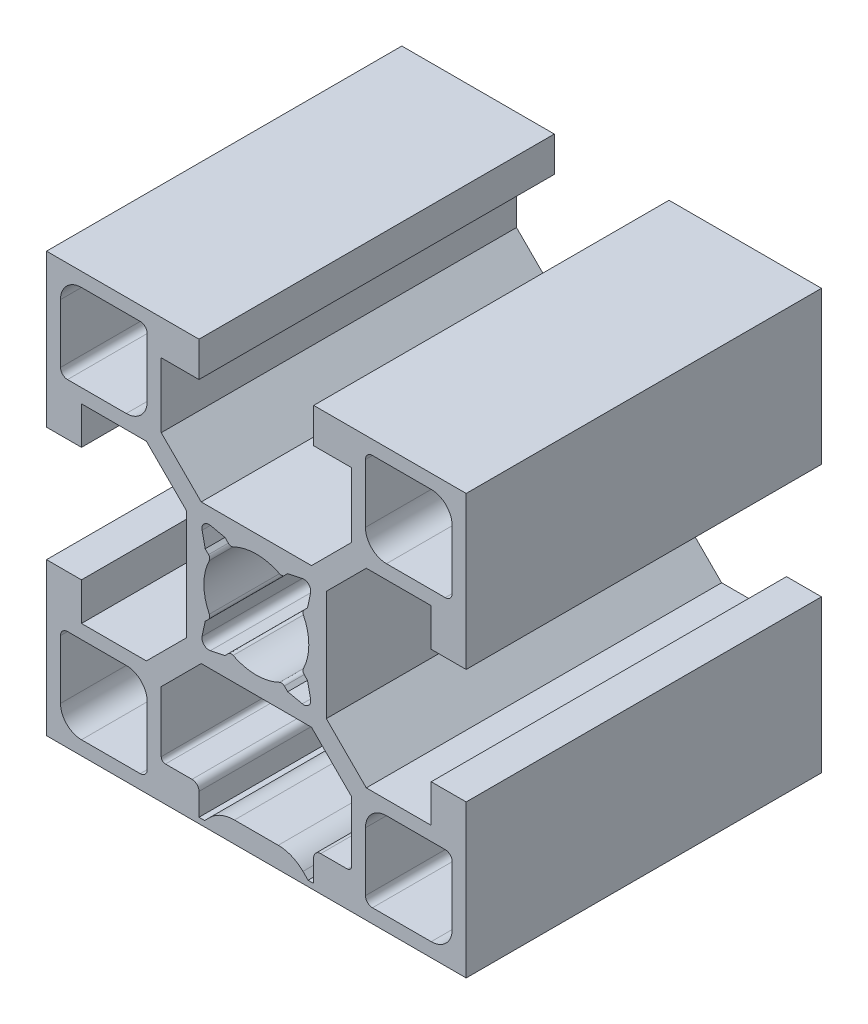
from build123d import *

# Parameters (mm, degrees)
EXTRUSION3_DEPTH = 25.4


with BuildPart() as part:
    # Sketch1 → Extrusion3 (new body)
    with BuildSketch(Plane.XY):
        Polygon((-15.000000011, 14.999999975), (-14.999999998, 4.099998455), (-12.499999998, 4.099998455), (-12.499999998, 6.799995405), (-7.860655598, 6.799995405), (-5.002158168, 3.941497975), (-5.002158168, -3.941498015), (-7.860655598, -6.799995445), (-12.499999998, -6.799995445), (-12.499999998, -4.099998495), (-14.999999998, -4.099998495), (-14.999999998, -15.000000015), (14.999999982, -15.000000015), (14.999999982, -4.099998495), (12.499999982, -4.099998495), (12.499999982, -6.799995445), (7.860655582, -6.799995445), (5.002158152, -3.941498015), (5.002158152, 3.941497975), (7.860655582, 6.799995405), (12.499999982, 6.799995405), (12.499999982, 4.099998455), (14.999999982, 4.099998455), (14.999999982, 14.999999975), (4.099998462, 14.999999975), (4.099998462, 12.499999975), (6.799995412, 12.499999975), (6.799995412, 7.860655575), (3.941497982, 5.002158145), (-3.941498008, 5.002158145), (-6.799995438, 7.860655575), (-6.799995438, 12.499999975), (-4.099998488, 12.499999975), (-4.099998488, 14.999999975), align=None)
        with BuildLine():
            Line((13.499999982, 7.799995395), (9.299995412, 7.799995395))
            ThreePointArc((9.299995412, 7.799995395), (8.239335242, 8.239335225), (7.799995412, 9.299995395))
            Line((7.799995412, 9.299995395), (7.799995412, 13.499999965))
            ThreePointArc((7.799995412, 13.499999965), (7.946442022, 13.853553355), (8.299995412, 13.999999965))
            Line((8.299995412, 13.999999965), (12.499999982, 13.999999965))
            ThreePointArc((12.499999982, 13.999999965), (13.560660152, 13.560660135), (13.999999982, 12.499999965))
            Line((13.999999982, 12.499999965), (13.999999982, 8.299995395))
            ThreePointArc((13.999999982, 8.299995395), (13.853553372, 7.946442005), (13.499999982, 7.799995395))
        make_face(mode=Mode.SUBTRACT)
        with BuildLine():
            Line((-7.799995428, 13.499999965), (-7.799995428, 9.299995395))
            ThreePointArc((-7.799995428, 9.299995395), (-8.239335258, 8.239335225), (-9.299995428, 7.799995395))
            Line((-9.299995428, 7.799995395), (-13.499999998, 7.799995395))
            ThreePointArc((-13.499999998, 7.799995395), (-13.853553388, 7.946442005), (-13.999999998, 8.299995395))
            Line((-13.999999998, 8.299995395), (-13.999999998, 12.499999965))
            ThreePointArc((-13.999999998, 12.499999965), (-13.560660168, 13.560660135), (-12.499999998, 13.999999965))
            Line((-12.499999998, 13.999999965), (-8.299995428, 13.999999965))
            ThreePointArc((-8.299995428, 13.999999965), (-7.946442038, 13.853553355), (-7.799995428, 13.499999965))
        make_face(mode=Mode.SUBTRACT)
        with BuildLine():
            Line((7.799995412, -13.500000015), (7.799995412, -9.299995445))
            ThreePointArc((7.799995412, -9.299995445), (8.239335242, -8.239335275), (9.299995412, -7.799995445))
            Line((9.299995412, -7.799995445), (13.499999982, -7.799995445))
            ThreePointArc((13.499999982, -7.799995445), (13.853553372, -7.946442055), (13.999999982, -8.299995445))
            Line((13.999999982, -8.299995445), (13.999999982, -12.500000015))
            ThreePointArc((13.999999982, -12.500000015), (13.560660152, -13.560660185), (12.499999982, -14.000000015))
            Line((12.499999982, -14.000000015), (8.299995412, -14.000000015))
            ThreePointArc((8.299995412, -14.000000015), (7.946442022, -13.853553405), (7.799995412, -13.500000015))
        make_face(mode=Mode.SUBTRACT)
        with BuildLine():
            Line((-13.499999998, -7.799995445), (-9.299995428, -7.799995445))
            ThreePointArc((-9.299995428, -7.799995445), (-8.239335258, -8.239335275), (-7.799995428, -9.299995445))
            Line((-7.799995428, -9.299995445), (-7.799995428, -13.500000015))
            ThreePointArc((-7.799995428, -13.500000015), (-7.946442038, -13.853553405), (-8.299995428, -14.000000015))
            Line((-8.299995428, -14.000000015), (-12.499999998, -14.000000015))
            ThreePointArc((-12.499999998, -14.000000015), (-13.560660168, -13.560660185), (-13.999999998, -12.500000015))
            Line((-13.999999998, -12.500000015), (-13.999999998, -8.299995445))
            ThreePointArc((-13.999999998, -8.299995445), (-13.853553388, -7.946442055), (-13.499999998, -7.799995445))
        make_face(mode=Mode.SUBTRACT)
        with BuildLine():
            Line((-3.285876608, 3.878886835), (-2.243073548, 3.657287075))
            Line((-2.243073548, 3.657287075), (-2.005134008, 3.419347535))
            ThreePointArc((-2.005134008, 3.419347535), (-1.841800007, 3.335474925), (-1.660187018, 3.362481085))
            ThreePointArc((-1.660187018, 3.362481085), (-2.3e-08, 3.749999985), (1.660186972, 3.362481085))
            ThreePointArc((1.660186972, 3.362481085), (1.841799961, 3.335474925), (2.005133962, 3.419347535))
            Line((2.005133962, 3.419347535), (2.243073502, 3.657287075))
            Line((2.243073502, 3.657287075), (3.285876562, 3.878886835))
            ThreePointArc((3.285876562, 3.878886835), (3.743361172, 3.743361195), (3.878886812, 3.285876585))
            Line((3.878886812, 3.285876585), (3.657287052, 2.243073525))
            Line((3.657287052, 2.243073525), (3.419347512, 2.005133985))
            ThreePointArc((3.419347512, 2.005133985), (3.335474902, 1.841799984), (3.362481062, 1.660186995))
            ThreePointArc((3.362481062, 1.660186995), (3.749999954, -2e-09), (3.362481062, -1.660186995))
            ThreePointArc((3.362481062, -1.660186995), (3.335474902, -1.841799984), (3.419347512, -2.005133985))
            Line((3.419347512, -2.005133985), (3.657287052, -2.243073525))
            Line((3.657287052, -2.243073525), (3.878886812, -3.285876585))
            ThreePointArc((3.878886812, -3.285876585), (3.743361172, -3.743361195), (3.285876562, -3.878886835))
            Line((3.285876562, -3.878886835), (2.243073502, -3.657287075))
            Line((2.243073502, -3.657287075), (2.005133962, -3.419347535))
            ThreePointArc((2.005133962, -3.419347535), (1.841799961, -3.335474925), (1.660186972, -3.362481085))
            ThreePointArc((1.660186972, -3.362481085), (-2.3e-08, -3.74999999), (-1.660187018, -3.362481085))
            ThreePointArc((-1.660187018, -3.362481085), (-1.841800007, -3.335474925), (-2.005134008, -3.419347535))
            Line((-2.005134008, -3.419347535), (-2.243073548, -3.657287075))
            Line((-2.243073548, -3.657287075), (-3.285876608, -3.878886835))
            ThreePointArc((-3.285876608, -3.878886835), (-3.743361218, -3.743361195), (-3.878886858, -3.285876585))
            Line((-3.878886858, -3.285876585), (-3.657287098, -2.243073525))
            Line((-3.657287098, -2.243073525), (-3.419347558, -2.005133985))
            ThreePointArc((-3.419347558, -2.005133985), (-3.335474948, -1.841799984), (-3.362481108, -1.660186995))
            ThreePointArc((-3.362481108, -1.660186995), (-3.750000021, -2e-09), (-3.362481108, 1.660186995))
            ThreePointArc((-3.362481108, 1.660186995), (-3.335474948, 1.841799984), (-3.419347558, 2.005133985))
            Line((-3.419347558, 2.005133985), (-3.657287098, 2.243073525))
            Line((-3.657287098, 2.243073525), (-3.878886858, 3.285876585))
            ThreePointArc((-3.878886858, 3.285876585), (-3.743361218, 3.743361195), (-3.285876608, 3.878886835))
        make_face(mode=Mode.SUBTRACT)
        with BuildLine():
            Line((-6.799995418, -7.860655625), (-3.941497998, -5.002158195))
            Line((-3.941497998, -5.002158195), (3.941497992, -5.002158195))
            Line((3.941497992, -5.002158195), (6.799995422, -7.860655625))
            Line((6.799995422, -7.860655625), (6.799995422, -12.199996975))
            ThreePointArc((6.799995422, -12.199996975), (6.712130925, -12.412130132), (6.500000002, -12.500000025))
            Line((6.500000002, -12.500000025), (4.599998472, -12.500000025))
            ThreePointArc((4.599998472, -12.500000025), (4.246445082, -12.646446635), (4.099998472, -13.000000025))
            Line((4.099998472, -13.000000025), (4.099998472, -14.600000025))
            Line((4.099998472, -14.600000025), (3.699990832, -14.600000025))
            Line((3.699990832, -14.600000025), (3.332307072, -14.232291555))
            ThreePointArc((3.332307072, -14.232291555), (2.521228054, -13.690316336), (1.564480612, -13.499999115))
            Line((1.564480612, -13.499999115), (-5.8e-08, -13.499999185))
            Line((-5.8e-08, -13.499999185), (-1.564449118, -13.499999135))
            ThreePointArc((-1.564449118, -13.499999135), (-2.521158976, -13.690300794), (-3.332218038, -14.232234065))
            Line((-3.332218038, -14.232234065), (-3.699983218, -14.600000025))
            Line((-3.699983218, -14.600000025), (-4.099998468, -14.600000025))
            Line((-4.099998468, -14.600000025), (-4.099998468, -13.000000025))
            ThreePointArc((-4.099998468, -13.000000025), (-4.246445078, -12.646446635), (-4.599998468, -12.500000025))
            Line((-4.599998468, -12.500000025), (-6.499999998, -12.500000025))
            ThreePointArc((-6.499999998, -12.500000025), (-6.712130926, -12.412130137), (-6.799995418, -12.199996975))
            Line((-6.799995418, -12.199996975), (-6.799995418, -7.860655625))
        make_face(mode=Mode.SUBTRACT)
    extrude(amount=EXTRUSION3_DEPTH)


solid = part.part
